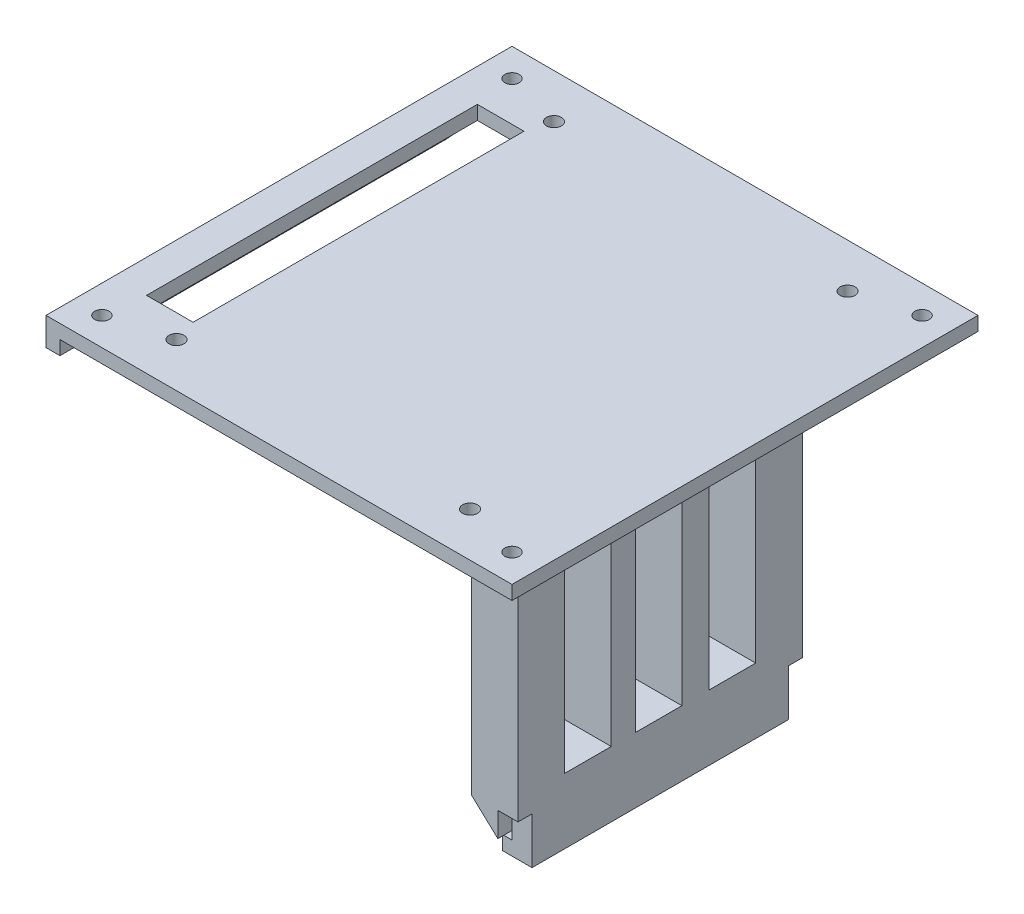
from build123d import *

# Parameters (mm, degrees)
CROQUIS1_W              = 100
CROQUIS1_H              = 100
SALIENTE_EXTRUIR1_DEPTH = 3
CROQUIS6_R              = 1.55
CORTAR_EXTRUIR4_DEPTH   = 10
CROQUIS7_R              = 1.6
CORTAR_EXTRUIR5_DEPTH   = 10
CROQUIS8_W              = 3
CROQUIS8_H              = 100
SALIENTE_EXTRUIR3_DEPTH = 3
CROQUIS9_W              = 10
CROQUIS9_H              = 61
SALIENTE_EXTRUIR4_DEPTH = 60
CROQUIS10_W             = 4.321859215
CROQUIS10_H             = 55
SALIENTE_EXTRUIR5_DEPTH = 10
CROQUIS11_W             = 55
CROQUIS11_H             = 3
SALIENTE_EXTRUIR6_DEPTH = 2
SALIENTE_EXTRUIR7_DEPTH = 61
CROQUIS13_W             = 10
CROQUIS13_H             = 71
CORTAR_EXTRUIR6_DEPTH   = 61
CROQUIS14_W             = 10
CROQUIS14_H             = 49
CORTAR_EXTRUIR7_DEPTH   = 61


with BuildPart() as part:
    # Croquis1 → Saliente-Extruir1 (new body)
    with BuildSketch(Plane(origin=(0, 0, 0), x_dir=(1, 0, 0), z_dir=(0, 1, 0))):
        Rectangle(CROQUIS1_W, CROQUIS1_H)
    extrude(amount=SALIENTE_EXTRUIR1_DEPTH)

    # Croquis6 → Cortar-Extruir4 (cut)
    with BuildSketch(Plane(origin=(0, 3, 0), x_dir=(1, 0, 0), z_dir=(0, 1, 0))):
        with Locations(Location((-44, 44, 0), (0, 0, 270))):  # turned: the seam where the file's is
            Circle(CROQUIS6_R)
        with Locations(Location((44, 44, 0), (0, 0, 270))):  # turned: the seam where the file's is
            Circle(CROQUIS6_R)
        with Locations(Location((44, -44, 0), (0, 0, 270))):  # turned: the seam where the file's is
            Circle(CROQUIS6_R)
        with Locations(Location((-44, -44, 0), (0, 0, 270))):  # turned: the seam where the file's is
            Circle(CROQUIS6_R)
    extrude(amount=-CORTAR_EXTRUIR4_DEPTH, mode=Mode.SUBTRACT)

    # Croquis7 → Cortar-Extruir5 (cut)
    with BuildSketch(Plane(origin=(0, 3, 0), x_dir=(1, 0, 0), z_dir=(0, 1, 0))):
        with Locations(Location((-31.5, 40.5, 0), (0, 0, 270))):  # turned: the seam where the file's is
            Circle(CROQUIS7_R)
        with Locations(Location((31.5, 40.5, 0), (0, 0, 270))):  # turned: the seam where the file's is
            Circle(CROQUIS7_R)
        with Locations(Location((-31.5, -40.5, 0), (0, 0, 270))):  # turned: the seam where the file's is
            Circle(CROQUIS7_R)
        with Locations(Location((31.5, -40.5, 0), (0, 0, 270))):  # turned: the seam where the file's is
            Circle(CROQUIS7_R)
    extrude(amount=-CORTAR_EXTRUIR5_DEPTH, mode=Mode.SUBTRACT)

    # Croquis8 → Saliente-Extruir3 (add)
    with BuildSketch(Plane.XZ):
        with Locations((-48.5, 0)):
            Rectangle(CROQUIS8_W, CROQUIS8_H)
    extrude(amount=SALIENTE_EXTRUIR3_DEPTH)

    # Croquis9 → Saliente-Extruir4 (add)
    with BuildSketch(Plane.XZ):
        with Locations((26.793549779, 0)):
            Rectangle(CROQUIS9_W, CROQUIS9_H)
    extrude(amount=SALIENTE_EXTRUIR4_DEPTH)

    # Croquis10 → Saliente-Extruir5 (add)
    with BuildSketch(Plane.XZ.offset(60)):
        with Locations((29.632620172, 0)):
            Rectangle(CROQUIS10_W, CROQUIS10_H)
    extrude(amount=SALIENTE_EXTRUIR5_DEPTH)

    # Croquis11 → Saliente-Extruir6 (add)
    with BuildSketch(Plane.ZY.offset(-27.471690564)):
        with Locations((0, -68.5)):
            Rectangle(CROQUIS11_W, CROQUIS11_H)
    extrude(amount=SALIENTE_EXTRUIR6_DEPTH)

    # Croquis12 → Saliente-Extruir7 (add)
    with BuildSketch(Plane.XY.offset(30.5)):
        Polygon((21.793549779, -60), (27.471690564, -60), (27.471690564, -65.263594713), align=None)
        Polygon((-44.699438936, -1.906763457), (-47, -1.906763457), (-47, 0), (-42.931883245, 0), align=None)
    extrude(amount=-SALIENTE_EXTRUIR7_DEPTH)

    # Croquis13 → Cortar-Extruir6 (cut)
    with BuildSketch(Plane.XZ):
        with Locations((-37.931883245, 0)):
            Rectangle(CROQUIS13_W, CROQUIS13_H)
    extrude(amount=-CORTAR_EXTRUIR6_DEPTH, mode=Mode.SUBTRACT)

    # Croquis14 → Cortar-Extruir7 (cut)
    with BuildSketch(Plane(origin=(31.793549779, 0, 0), x_dir=(0, 0, -1), z_dir=(1, 0, 0))):
        with Locations((-15.5, -31.474245952)):
            Rectangle(CROQUIS14_W, CROQUIS14_H)
        with Locations((-0.336542235, -31.474245952)):
            Rectangle(CROQUIS14_W, CROQUIS14_H)
        with Locations((15.5, -31.474245952)):
            Rectangle(CROQUIS14_W, CROQUIS14_H)
    extrude(amount=-CORTAR_EXTRUIR7_DEPTH, mode=Mode.SUBTRACT)


solid = part.part
